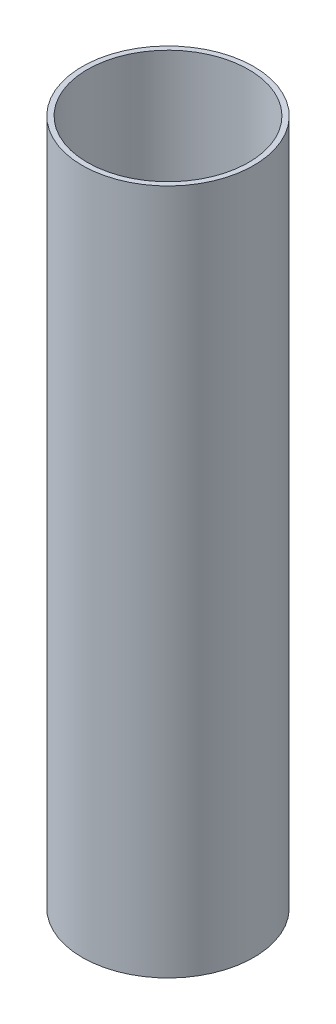
from build123d import *

# Parameters (mm, degrees)
SKETCH1_R           = 6.35
SKETCH1_R_2         = 5.969
BOSS_EXTRUDE1_DEPTH = 50.8


with BuildPart() as part:
    # Sketch1 → Boss-Extrude1 (new body)
    with BuildSketch(Plane(origin=(0, 0, 0), x_dir=(1, 0, 0), z_dir=(0, 1, 0))):
        Circle(SKETCH1_R)
        Circle(SKETCH1_R_2, mode=Mode.SUBTRACT)
    extrude(amount=BOSS_EXTRUDE1_DEPTH)


solid = part.part
